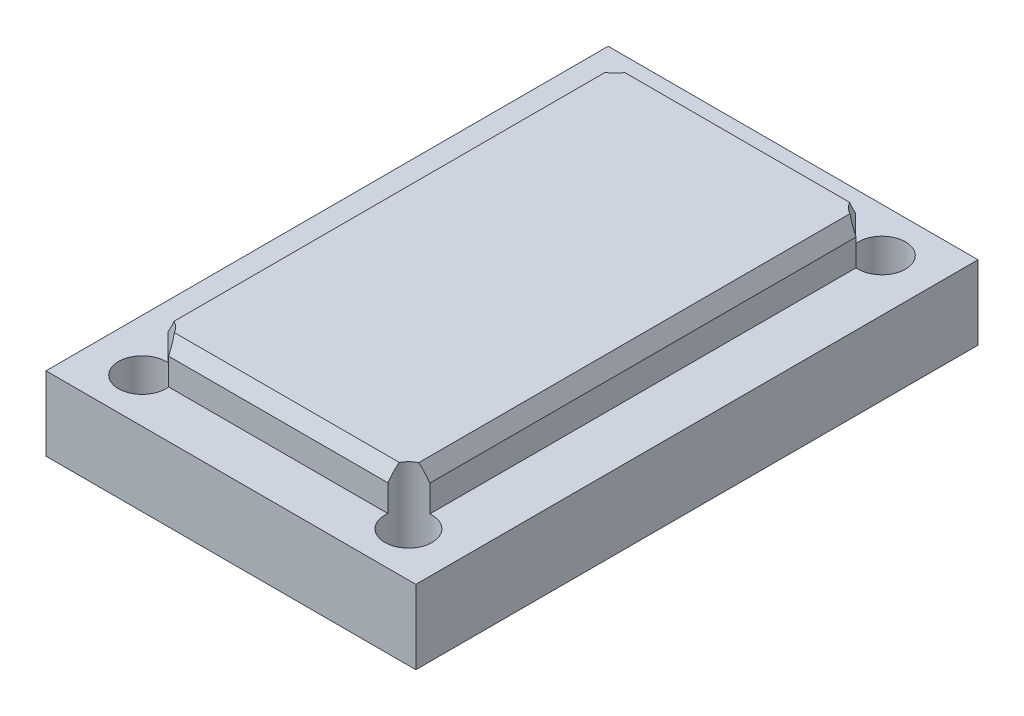
from build123d import *

# Parameters (mm, degrees)
SKETCH1_W               = 25
SKETCH1_H               = 38
BOSS_EXTRUDE1_DEPTH     = 5
SKETCH4_R               = 4.15
CUT_EXTRUDE2_DEPTH      = 6
SKETCH9_W               = 17.7
SKETCH9_H               = 31.6
BOSS_EXTRUDE3_DEPTH     = 2.8
SKETCH6_R               = 1.6
CUT_EXTRUDE4_DEPTH      = 3.8
CUT_EXTRUDE4_DEPTH_BACK = 6
CHAMFER1_SIZE           = 1
CHAMFER1_SIZE2          = 0.577350269
CHAMFER1_PART_2_SIZE    = 1
CHAMFER1_PART_2_SIZE2   = 0.577350269
CHAMFER1_PART_3_SIZE    = 1
CHAMFER1_PART_3_SIZE2   = 0.577350269
CHAMFER1_PART_4_SIZE    = 1
CHAMFER1_PART_4_SIZE2   = 0.577350269
SKETCH10_R              = 4.15
BOSS_EXTRUDE4_DEPTH     = 5


with BuildPart() as part:
    # Sketch1 → Boss-Extrude1 (new body)
    with BuildSketch(Plane(origin=(0, 0, 0), x_dir=(1, 0, 0), z_dir=(0, 1, 0))):
        Rectangle(SKETCH1_W, SKETCH1_H)
    extrude(amount=BOSS_EXTRUDE1_DEPTH)

    # Sketch4 → Cut-Extrude2 (cut, through all)
    with BuildSketch(Plane(origin=(0, 5, 0), x_dir=(1, 0, 0), z_dir=(0, 1, 0))):
        Circle(SKETCH4_R)
    extrude(amount=-CUT_EXTRUDE2_DEPTH, mode=Mode.SUBTRACT)

    # Sketch9 → Boss-Extrude3 (add)
    with BuildSketch(Plane(origin=(0, 5, 0), x_dir=(1, 0, 0), z_dir=(0, 1, 0))):
        Rectangle(SKETCH9_W, SKETCH9_H)
    extrude(amount=BOSS_EXTRUDE3_DEPTH)

    # Sketch6 → Cut-Extrude4 (cut, two sides)
    with BuildSketch(Plane(origin=(0, 5, 0), x_dir=(1, 0, 0), z_dir=(0, 1, 0))) as cut_extrude4_sk:
        with Locations((9, -16)):
            Circle(SKETCH6_R)
        with Locations((-9, -16)):
            Circle(SKETCH6_R)
        with Locations((-9, 16)):
            Circle(SKETCH6_R)
        with Locations((9, 16)):
            Circle(SKETCH6_R)
    extrude(amount=CUT_EXTRUDE4_DEPTH, mode=Mode.SUBTRACT)
    extrude(cut_extrude4_sk.sketch, amount=-CUT_EXTRUDE4_DEPTH_BACK, mode=Mode.SUBTRACT)

    # Chamfer1
    chamfer1_edges = [part.edges().sort_by_distance(p)[0] for p in [
        (8.85, 7.8, 0),
    ]]
    chamfer1_side = [part.faces().sort_by_distance(p)[0] for p in [
        (8.85, 6.4, 0),
    ]]
    chamfer(chamfer1_edges, length=CHAMFER1_SIZE, length2=CHAMFER1_SIZE2, reference=chamfer1_side[0])

    # Chamfer1 part 2
    chamfer1_part_2_edges = [part.edges().sort_by_distance(p)[0] for p in [
        (0, 7.8, 15.8),
    ]]
    chamfer1_part_2_side = [part.faces().sort_by_distance(p)[0] for p in [
        (0, 6.4, 15.8),
    ]]
    chamfer(chamfer1_part_2_edges, length=CHAMFER1_PART_2_SIZE, length2=CHAMFER1_PART_2_SIZE2, reference=chamfer1_part_2_side[0])

    # Chamfer1 part 3
    chamfer1_part_3_edges = [part.edges().sort_by_distance(p)[0] for p in [
        (0, 7.8, -15.8),
    ]]
    chamfer1_part_3_side = [part.faces().sort_by_distance(p)[0] for p in [
        (0, 6.4, -15.8),
    ]]
    chamfer(chamfer1_part_3_edges, length=CHAMFER1_PART_3_SIZE, length2=CHAMFER1_PART_3_SIZE2, reference=chamfer1_part_3_side[0])

    # Chamfer1 part 4
    chamfer1_part_4_edges = [part.edges().sort_by_distance(p)[0] for p in [
        (-8.85, 7.8, 0),
    ]]
    chamfer1_part_4_side = [part.faces().sort_by_distance(p)[0] for p in [
        (-8.85, 6.4, 0),
    ]]
    chamfer(chamfer1_part_4_edges, length=CHAMFER1_PART_4_SIZE, length2=CHAMFER1_PART_4_SIZE2, reference=chamfer1_part_4_side[0])

    # Sketch10 → Boss-Extrude4 (add)
    with BuildSketch(Plane.XZ.offset(-5)):
        Circle(SKETCH10_R)
    extrude(amount=BOSS_EXTRUDE4_DEPTH)


solid = part.part
